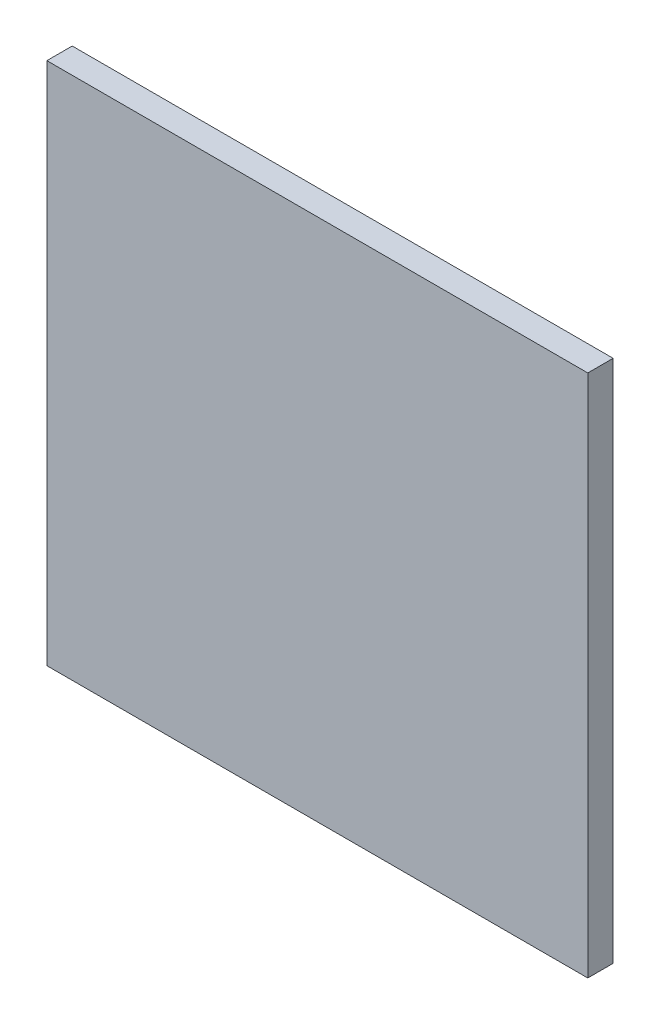
from build123d import *

# Parameters (mm, degrees)
ESQUISSE1_W        = 32
ESQUISSE1_H        = 31
BOSS_EXTRU_1_DEPTH = 0.75


with BuildPart() as part:
    # Esquisse1 → Boss.-Extru.1 (new body, symmetric)
    with BuildSketch(Plane.XY):
        Rectangle(ESQUISSE1_W, ESQUISSE1_H)
    extrude(amount=BOSS_EXTRU_1_DEPTH, both=True)


solid = part.part
